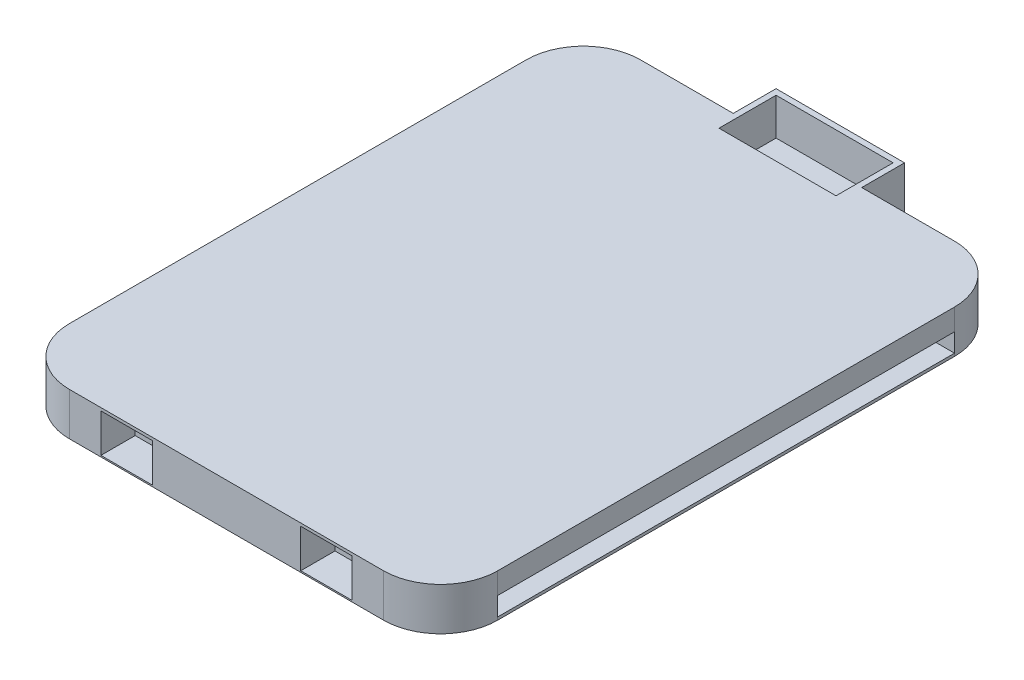
from build123d import *

# Parameters (mm, degrees)
BOSS_EXTRUDE1_DEPTH     = 150
SKETCH2_W               = 400
SKETCH2_H               = 65
CUT_EXTRUDE1_DEPTH      = 1
CUT_EXTRUDE1_DEPTH_BACK = 1501
SKETCH3_W               = 600
SKETCH3_H               = 65
CUT_EXTRUDE2_DEPTH      = 130
SKETCH4_R               = 5
BOSS_EXTRUDE2_DEPTH     = 150
SKETCH5_W               = 90
SKETCH5_H               = 75
CUT_EXTRUDE3_DEPTH      = 200
SKETCH6_R               = 15
CUT_EXTRUDE4_DEPTH      = 5
SKETCH7_W               = 180
SKETCH7_H               = 135
CUT_EXTRUDE5_DEPTH      = 120
CUT_EXTRUDE6_START      = -20
SKETCH8_W               = 410
SKETCH8_H               = 110
SKETCH8_R               = 15
CUT_EXTRUDE6_DEPTH      = 200
SKETCH9_W               = 410
SKETCH9_H               = 200
CUT_EXTRUDE7_DEPTH      = 127


with BuildPart() as part:
    # Sketch1 → Boss-Extrude1 (new body)
    with BuildSketch(Plane(origin=(0, 0, 0), x_dir=(1, 0, 0), z_dir=(0, 1, 0))):
        with BuildLine():
            Line((-225, 1000), (-225, 1150))
            Line((-225, 1150), (225, 1150))
            Line((225, 1150), (225, 1000))
            Line((225, 1000), (550, 1000))
            ThreePointArc((550, 1000), (691.421356237, 941.421356237), (750, 800))
            Line((750, 800), (750, -800))
            ThreePointArc((750, -800), (691.421356237, -941.421356237), (550, -1000))
            Line((550, -1000), (-550, -1000))
            ThreePointArc((-550, -1000), (-691.421356237, -941.421356237), (-750, -800))
            Line((-750, -800), (-750, 800))
            ThreePointArc((-750, 800), (-691.421356237, 941.421356237), (-550, 1000))
            Line((-550, 1000), (-225, 1000))
        make_face()
    extrude(amount=BOSS_EXTRUDE1_DEPTH)

    # Sketch2 → Cut-Extrude1 (cut, two sides)
    with BuildSketch(Plane(origin=(750, 0, 0), x_dir=(0, 0, -1), z_dir=(1, 0, 0))) as cut_extrude1_sk:
        with Locations((0, 42.5)):
            Rectangle(SKETCH2_W, SKETCH2_H)
    extrude(amount=CUT_EXTRUDE1_DEPTH, mode=Mode.SUBTRACT)
    extrude(cut_extrude1_sk.sketch, amount=-CUT_EXTRUDE1_DEPTH_BACK, mode=Mode.SUBTRACT)

    # Sketch3 → Cut-Extrude2 (cut)
    with BuildSketch(Plane(origin=(750, 0, 0), x_dir=(0, 0, -1), z_dir=(1, 0, 0))):
        with Locations((500, 42.5)):
            Rectangle(SKETCH3_W, SKETCH3_H)
        with Locations((-500, 42.5)):
            Rectangle(SKETCH3_W, SKETCH3_H)
    cut_extrude2 = extrude(amount=-CUT_EXTRUDE2_DEPTH, mode=Mode.SUBTRACT)

    # Mirror1: Cut-Extrude2 across plane
    add(cut_extrude2.mirror(Plane(origin=(0, 0, 0), x_dir=(0, 0, 1), z_dir=(1, 0, 0))), mode=Mode.SUBTRACT)

    # Sketch4 → Boss-Extrude2 (add)
    with BuildSketch(Plane(origin=(0, 150, 0), x_dir=(1, 0, 0), z_dir=(0, 1, 0))):
        with Locations((-670, 100)):
            Circle(SKETCH4_R)
        with Locations((-670, -100)):
            Circle(SKETCH4_R)
    boss_extrude2 = extrude(amount=-BOSS_EXTRUDE2_DEPTH)

    # Mirror2: Boss-Extrude2 across plane
    add(boss_extrude2.mirror(Plane(origin=(0, 0, 0), x_dir=(0, 0, 1), z_dir=(1, 0, 0))))

    # Sketch5 → Cut-Extrude3 (cut)
    with BuildSketch(Plane.XY.offset(1000)):
        with Locations((-350, 72.5)):
            Rectangle(SKETCH5_W, SKETCH5_H)
        with Locations((350, 72.5)):
            Rectangle(SKETCH5_W, SKETCH5_H)
    extrude(amount=-CUT_EXTRUDE3_DEPTH, mode=Mode.SUBTRACT)

    # Sketch6 → Cut-Extrude4 (cut)
    with BuildSketch(Plane(origin=(0, 0, -1150), x_dir=(-1, 0, 0), z_dir=(0, 0, -1))):
        with Locations((0, 75)):
            Circle(SKETCH6_R)
    extrude(amount=-CUT_EXTRUDE4_DEPTH, mode=Mode.SUBTRACT)

    # Sketch7 → Cut-Extrude5 (cut)
    with BuildSketch(Plane.XY.offset(1000)):
        with Locations((-350, 72.5)):
            Rectangle(SKETCH7_W, SKETCH7_H)
        with Locations((350, 72.5)):
            Rectangle(SKETCH7_W, SKETCH7_H)
    extrude(amount=-CUT_EXTRUDE5_DEPTH, mode=Mode.SUBTRACT)

    # Sketch8 → Cut-Extrude6 (cut)
    with BuildSketch(Plane(origin=(0, 0, -1150), x_dir=(-1, 0, 0), z_dir=(0, 0, -1)).offset(CUT_EXTRUDE6_START)):
        with Locations((0, 75)):
            Rectangle(SKETCH8_W, SKETCH8_H)
        with Locations((0, 75)):
            Circle(SKETCH8_R, mode=Mode.SUBTRACT)
    extrude(amount=-CUT_EXTRUDE6_DEPTH, mode=Mode.SUBTRACT)

    # Sketch9 → Cut-Extrude7 (cut)
    with BuildSketch(Plane(origin=(0, 150, 0), x_dir=(1, 0, 0), z_dir=(0, 1, 0))):
        with Locations((0, 1030)):
            Rectangle(SKETCH9_W, SKETCH9_H)
    extrude(amount=-CUT_EXTRUDE7_DEPTH, mode=Mode.SUBTRACT)


solid = part.part
